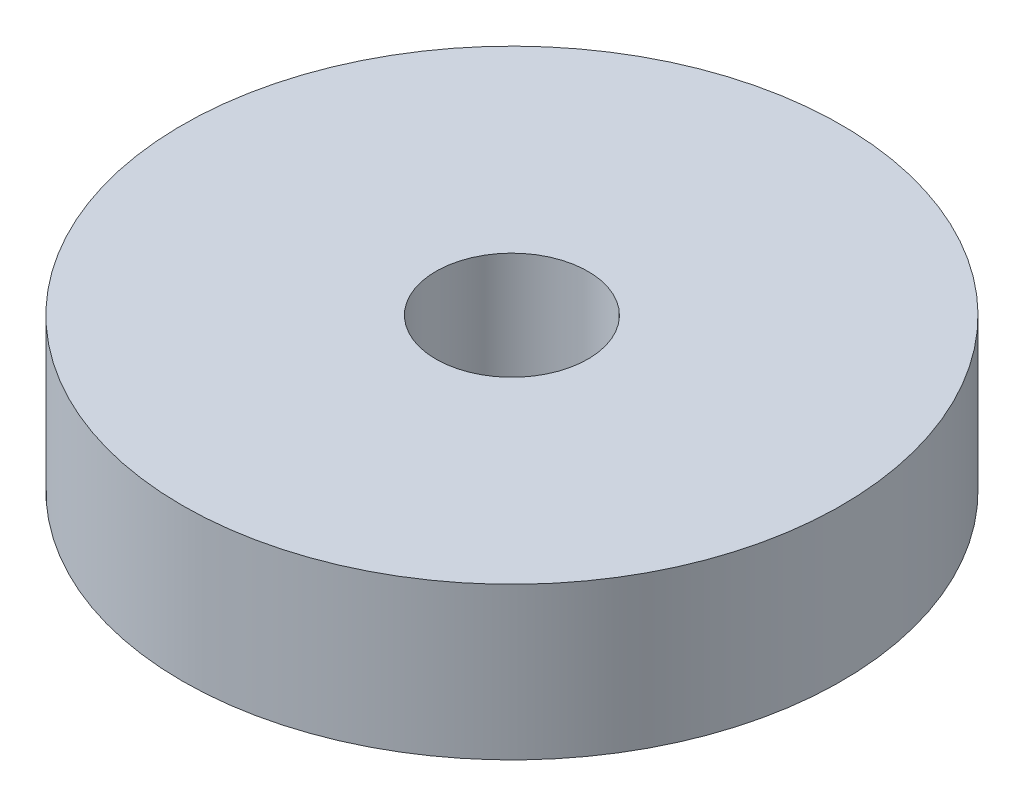
from build123d import *

# Parameters (mm, degrees)
SKETCH_1_R      = 6.5
SKETCH_1_R_2    = 1.5
EXTRUDE_1_DEPTH = 3


with BuildPart() as part:
    # 草图1 → 凸台-拉伸1 (new body)
    with BuildSketch(Plane(origin=(0, 0, 0), x_dir=(1, 0, 0), z_dir=(0, 1, 0))):
        Circle(SKETCH_1_R)
        Circle(SKETCH_1_R_2, mode=Mode.SUBTRACT)
    extrude(amount=EXTRUDE_1_DEPTH)


solid = part.part
